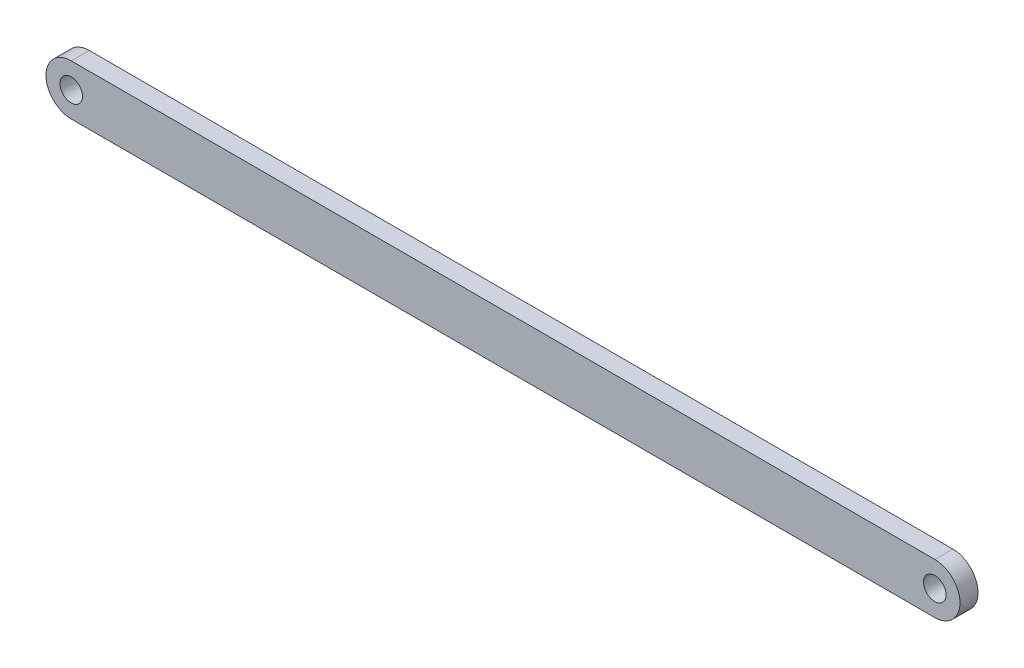
from build123d import *

# Parameters (mm, degrees)
BOSS_EXTRUDE1_DEPTH = 3.175


with BuildPart() as part:
    # Sketch1 → Boss-Extrude1 (new body)
    with BuildSketch(Plane.XY):
        with BuildLine():
            Line((76.2, 4.445), (-76.2, 4.445))
            ThreePointArc((-76.2, 4.445), (-73.056910358, 3.143089642), (-71.755, 0))
            ThreePointArc((-71.755, 0), (-73.056910358, -3.143089642), (-76.2, -4.445))
            Line((-76.2, -4.445), (76.2, -4.445))
            ThreePointArc((76.2, -4.445), (71.755, 0), (76.2, 4.445))
        make_face()
        with BuildLine():
            ThreePointArc((-71.755, 0), (-73.056910358, 3.143089642), (-76.2, 4.445))
            Line((-76.2, 4.445), (-76.2, 1.9939))
            ThreePointArc((-76.2, 1.9939), (-74.790099789, 1.409900211), (-74.2061, 0))
            ThreePointArc((-74.2061, 0), (-74.790099789, -1.409900211), (-76.2, -1.9939))
            Line((-76.2, -1.9939), (-76.2, -4.445))
            ThreePointArc((-76.2, -4.445), (-73.056910358, -3.143089642), (-71.755, 0))
        make_face()
        with BuildLine():
            Line((-76.2, 1.9939), (-76.2, 4.445))
            ThreePointArc((-76.2, 4.445), (-80.645, 0), (-76.2, -4.445))
            Line((-76.2, -4.445), (-76.2, -1.9939))
            ThreePointArc((-76.2, -1.9939), (-78.1939, 0), (-76.2, 1.9939))
        make_face()
        with BuildLine():
            ThreePointArc((80.645, 0), (79.343089642, 3.143089642), (76.2, 4.445))
            Line((76.2, 4.445), (76.2, 1.9939))
            ThreePointArc((76.2, 1.9939), (77.609900211, 1.409900211), (78.1939, 0))
            ThreePointArc((78.1939, 0), (77.609900211, -1.409900211), (76.2, -1.9939))
            Line((76.2, -1.9939), (76.2, -4.445))
            ThreePointArc((76.2, -4.445), (79.343089642, -3.143089642), (80.645, 0))
        make_face()
        with BuildLine():
            Line((76.2, 1.9939), (76.2, 4.445))
            ThreePointArc((76.2, 4.445), (71.755, 0), (76.2, -4.445))
            Line((76.2, -4.445), (76.2, -1.9939))
            ThreePointArc((76.2, -1.9939), (74.2061, 0), (76.2, 1.9939))
        make_face()
    extrude(amount=BOSS_EXTRUDE1_DEPTH)


solid = part.part
